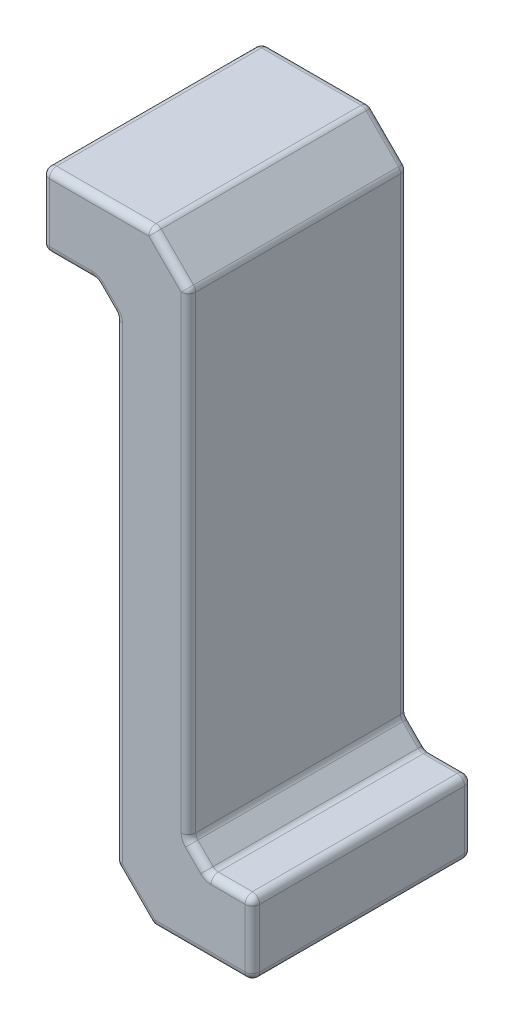
from build123d import *

# Parameters (mm, degrees)
SKETCH1_W           = 12
SKETCH1_H           = 4
BOSS_EXTRUDE1_DEPTH = 8
SKETCH2_W           = 4
SKETCH2_H           = 12
BOSS_EXTRUDE2_DEPTH = 25
SKETCH3_W           = 7.5
SKETCH3_H           = 12
BOSS_EXTRUDE3_DEPTH = 4
CHAMFER1_SIZE       = 2
RIB1_REACH          = 35.425
SKETCH4_WALL_W      = 70.36529828
SKETCH4_WALL_H      = 12
RIB2_REACH          = 35.425
SKETCH5_WALL_W      = 70.36529828
SKETCH5_WALL_H      = 12
SKETCH7_R           = 1
CUT_EXTRUDE2_DEPTH  = 4
FILLET1_R           = 0.4


with BuildPart() as part:
    # Sketch1 → Boss-Extrude1 (new body)
    with BuildSketch(Plane(origin=(0, 0, 0), x_dir=(0, 0, -1), z_dir=(1, 0, 0))):
        with Locations((6, 2)):
            Rectangle(SKETCH1_W, SKETCH1_H)
    extrude(amount=BOSS_EXTRUDE1_DEPTH)

    # Sketch2 → Boss-Extrude2 (add)
    with BuildSketch(Plane.XZ):
        with Locations((6, -6)):
            Rectangle(SKETCH2_W, SKETCH2_H)
    extrude(amount=BOSS_EXTRUDE2_DEPTH)

    # Sketch3 → Boss-Extrude3 (add)
    with BuildSketch(Plane.XZ.offset(25)):
        with Locations((7.75, -6)):
            Rectangle(SKETCH3_W, SKETCH3_H)
    extrude(amount=BOSS_EXTRUDE3_DEPTH)

    # Chamfer1
    chamfer1_edges = [part.edges().sort_by_distance(p)[0] for p in [
        (8, 4, -6),
        (4, -29, -6),
    ]]
    chamfer(chamfer1_edges, length=CHAMFER1_SIZE)

    # Sketch4 wall → Rib1 (add, up to next)
    with BuildSketch(Plane(origin=(3.464466094, -0.535533906, -12), x_dir=(0.707106781187, -0.707106781187, 0), z_dir=(-0.707106781187, -0.707106781187, 0)), mode=Mode.PRIVATE) as rib1_sk1:
        with Locations((0, 6)):
            Rectangle(SKETCH4_WALL_W, SKETCH4_WALL_H)
    rib1_tool1 = extrude(rib1_sk1.sketch, amount=-RIB1_REACH, mode=Mode.PRIVATE) - part.part
    add(rib1_tool1.solids().sort_by_distance((3.464466094, -0.535533906, -12))[0])

    # Sketch5 wall → Rib2 (add, up to next)
    with BuildSketch(Plane(origin=(8.535533906, -24.464466094, 0), x_dir=(0.707106781187, -0.707106781187, 0), z_dir=(0.707106781187, 0.707106781187, 0)), mode=Mode.PRIVATE) as rib2_sk1:
        with Locations((0, 6)):
            Rectangle(SKETCH5_WALL_W, SKETCH5_WALL_H)
    rib2_tool1 = extrude(rib2_sk1.sketch, amount=-RIB2_REACH, mode=Mode.PRIVATE) - part.part
    add(rib2_tool1.solids().sort_by_distance((8.535533906, -24.464466094, 0))[0])

    # Sketch7 → Cut-Extrude2 (cut)
    with BuildSketch(Plane.ZY):
        with Locations((-6, 2)):
            Circle(SKETCH7_R)
    extrude(amount=-CUT_EXTRUDE2_DEPTH, mode=Mode.SUBTRACT)

    # Fillet1
    fillet1_edges = [part.edges().sort_by_distance(p)[0] for p in [
        (11.5, -25, -6),
        (11.5, -27, -12),
        (10.285533906, -25, 0),
        (11.5, -27, 0),
        (11.5, -29, -6),
        (8.75, -29, 0),
        (8.75, -29, -12),
        (6, -29, -6),
        (3, 4, -12),
        (4, -14.035533906, -12),
        (7, 3, -12),
        (5, -28, -12),
        (4, -14.035533906, 0),
        (4, -27, -6),
        (8, -10.964466094, 0),
        (3, 4, 0),
        (7, 3, 0),
        (5, -28, 0),
        (0, 4, -6),
        (8, 2, -6),
        (6, 4, -6),
        (0, 2, -12),
        (0, 0, -6),
        (4, -1.071067812, -6),
        (0, 2, 0),
        (1.464466094, 0, -12),
        (1.464466094, 0, 0),
        (3.464466094, -0.535533906, -12),
        (2.928932188, 0, -6),
        (3.464466094, -0.535533906, 0),
        (10.285533906, -25, -12),
        (9.071067812, -25, -6),
        (8, -10.964466094, -12),
        (8.535533906, -24.464466094, 0),
        (8.535533906, -24.464466094, -12),
        (8, -23.928932188, -6),
    ]]
    fillet(fillet1_edges, radius=FILLET1_R)


solid = part.part
